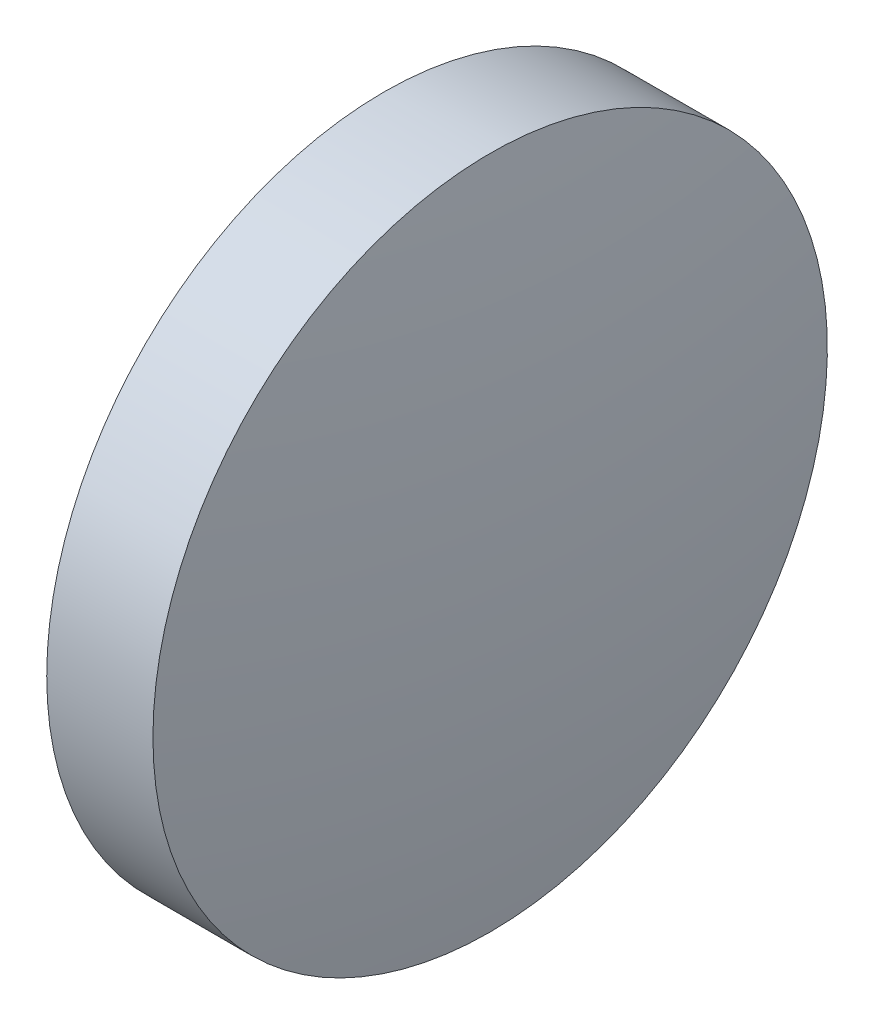
from build123d import *

# Parameters (mm, degrees)
SKETCH_1_ONE_SIDE_W = 2.000068571
SKETCH_1_ONE_SIDE_H = 6.35


with BuildPart() as part:
    # 草图1 one side → 旋转1 (revolve)
    with BuildSketch(Plane.XY, mode=Mode.PRIVATE) as revolve_1_sk:
        with Locations((43.229096888, 27.483056512)):
            Rectangle(SKETCH_1_ONE_SIDE_W, SKETCH_1_ONE_SIDE_H)
        with BuildLine():
            Line((41.729099887, 24.308056512), (42.229062602, 24.308056512))
            Line((42.229062602, 24.308056512), (42.229062602, 30.658056512))
            ThreePointArc((42.229062602, 30.658056512), (41.854283675, 27.492882359), (41.729099887, 24.308056512))
        make_face()
        with BuildLine():
            Line((44.229131173, 24.308056512), (44.729093887, 24.308056512))
            ThreePointArc((44.729093887, 24.308056512), (44.6039101, 27.492882359), (44.229131173, 30.658056512))
            Line((44.229131173, 30.658056512), (44.229131173, 24.308056512))
        make_face()
    revolve(revolve_1_sk.sketch.rotate(Axis((39.652700675, 24.308056512, 0), (1, 0, 0)), 90), axis=Axis((39.652700675, 24.308056512, 0), (1, 0, 0)))  # turned: the seam where the file's is


solid = part.part
